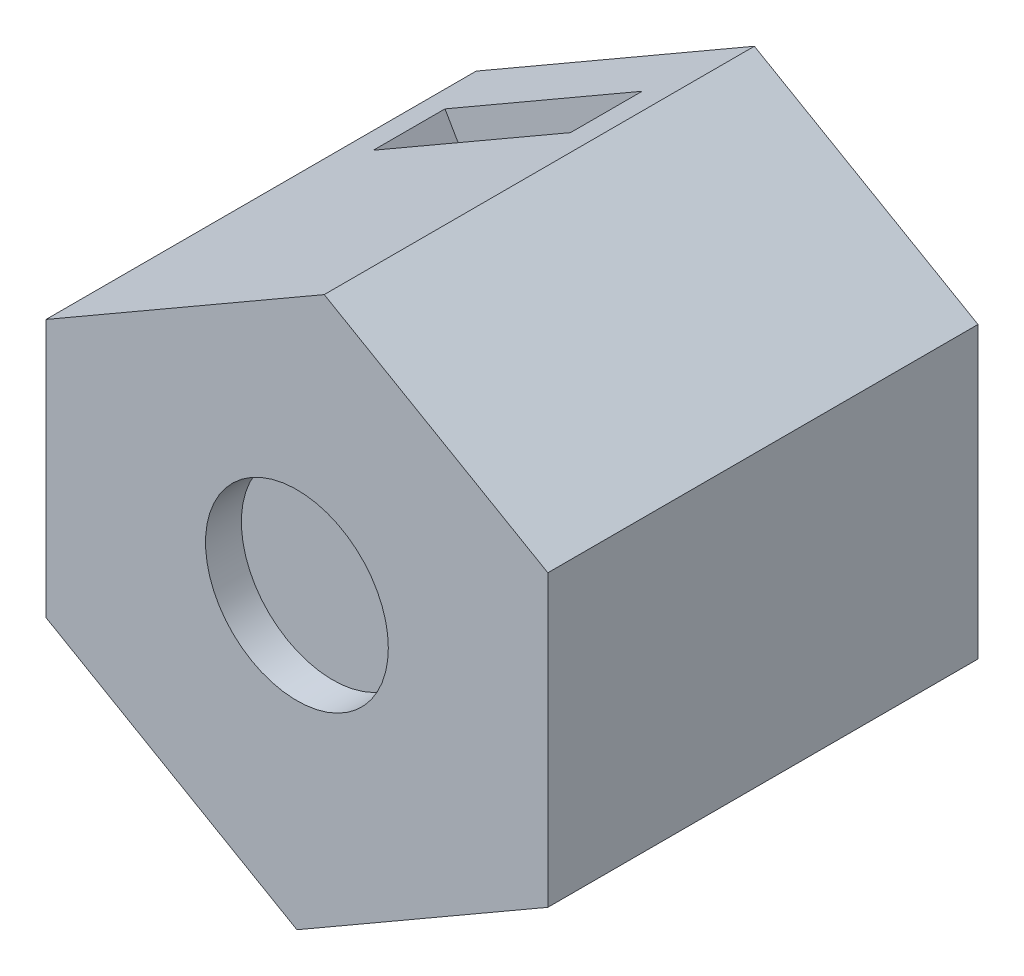
from build123d import *

# Parameters (mm, degrees)
SKETCH1_R           = 7
BOSS_EXTRUDE1_DEPTH = 12
SKETCH2_R           = 2.55
CUT_EXTRUDE1_DEPTH  = 1
SKETCH3_R           = 1.5
CUT_EXTRUDE2_DEPTH  = 4
CUT_EXTRUDE3_DEPTH  = 2
SKETCH5_W           = 6.350852962
SKETCH5_H           = 2
CUT_EXTRUDE4_DEPTH  = 5
SKETCH5_2_W         = 6.350852962
SKETCH5_2_H         = 2
CUT_EXTRUDE5_DEPTH  = 2.7
SKETCH6_R           = 1.5
CUT_EXTRUDE6_DEPTH  = 7
BOSS_EXTRUDE2_DEPTH = 12
CUT_EXTRUDE7_DEPTH  = 12
CUT_EXTRUDE8_DEPTH  = 12


with BuildPart() as part:
    # Sketch1 → Boss-Extrude1 (new body)
    with BuildSketch(Plane.XY):
        Circle(SKETCH1_R)
    extrude(amount=BOSS_EXTRUDE1_DEPTH)

    # Sketch2 → Cut-Extrude1 (cut)
    with BuildSketch(Plane.XY.offset(12)):
        Circle(SKETCH2_R)
    extrude(amount=-CUT_EXTRUDE1_DEPTH, mode=Mode.SUBTRACT)

    # Sketch3 → Cut-Extrude2 (cut)
    with BuildSketch(Plane(origin=(0, 0, 0), x_dir=(-1, 0, 0), z_dir=(0, 0, -1))):
        Circle(SKETCH3_R)
    extrude(amount=-CUT_EXTRUDE2_DEPTH, mode=Mode.SUBTRACT)

    # Sketch4 → Cut-Extrude3 (cut)
    with BuildSketch(Plane(origin=(0, 0, 4), x_dir=(-1, 0, 0), z_dir=(0, 0, -1))):
        Polygon((0, 3.175426481), (-2.75, 1.58771324), (-2.75, -1.58771324), (0, -3.175426481), (2.75, -1.58771324), (2.75, 1.58771324), align=None)
    extrude(amount=CUT_EXTRUDE3_DEPTH, mode=Mode.SUBTRACT)

    # Sketch5 → Cut-Extrude4 (cut)
    with BuildSketch(Plane(origin=(-1.375, 2.38156986, 0), x_dir=(0.866025404, 0.5, 0), z_dir=(0.5, -0.866025404, 0))):
        with Locations((0, 3)):
            Rectangle(SKETCH5_W, SKETCH5_H)
    extrude(amount=-CUT_EXTRUDE4_DEPTH, mode=Mode.SUBTRACT)

    # Sketch5_2 → Cut-Extrude5 (cut)
    with BuildSketch(Plane(origin=(-1.375, 2.38156986, 0), x_dir=(0.866025404, 0.5, 0), z_dir=(0.5, -0.866025404, 0))):
        with Locations((0, 3)):
            Rectangle(SKETCH5_2_W, SKETCH5_2_H)
    extrude(amount=CUT_EXTRUDE5_DEPTH, mode=Mode.SUBTRACT)

    # Sketch6 → Cut-Extrude6 (cut)
    with BuildSketch(Plane(origin=(0, 0, 0), x_dir=(-1, 0, 0), z_dir=(0, 0, -1))):
        Circle(SKETCH6_R)
    extrude(amount=-CUT_EXTRUDE6_DEPTH, mode=Mode.SUBTRACT)

    # Sketch7 → Boss-Extrude2 (add)
    with BuildSketch(Plane.XY.offset(12)):
        with BuildLine():
            Line((-5.869161212, 3.814832456), (-6.25, 4.474464586))
            Line((-6.25, 4.474464586), (-7, 4.041451884))
            Line((-7, 4.041451884), (-7, 0))
            ThreePointArc((-7, 0), (-6.711338484, 1.989456146), (-5.869161212, 3.814832456))
        make_face()
        with BuildLine():
            Line((3.499999838, 6.06217792), (0, 8.082903769))
            Line((0, 8.082903769), (-0.75, 7.649891067))
            Line((-0.75, 7.649891067), (-0.369161212, 6.990258937))
            ThreePointArc((-0.369161212, 6.990258937), (1.632749589, 6.806917715), (3.499999838, 6.06217792))
        make_face()
        with BuildLine():
            Line((7, 4.041451884), (3.499999838, 6.06217792))
            ThreePointArc((3.499999838, 6.06217792), (6.06217778, 3.500000081), (7, 0))
            Line((7, 0), (7, 4.041451884))
        make_face()
        with BuildLine():
            Line((7, -4.041451884), (7, 0))
            ThreePointArc((7, 0), (6.062177778, -3.500000084), (3.499999831, -6.062177924))
            Line((3.499999831, -6.062177924), (7, -4.041451884))
        make_face()
        with BuildLine():
            Line((0, -8.082903769), (3.499999831, -6.062177924))
            ThreePointArc((3.499999831, -6.062177924), (-1.13e-07, -7), (-3.500000026, -6.062177811))
            Line((-3.500000026, -6.062177811), (0, -8.082903769))
        make_face()
        with BuildLine():
            ThreePointArc((-3.500000026, -6.062177811), (-6.062177834, -3.499999987), (-7, 0))
            Line((-7, 0), (-7, -4.041451884))
            Line((-7, -4.041451884), (-3.500000026, -6.062177811))
        make_face()
    extrude(amount=-BOSS_EXTRUDE2_DEPTH)

    # Sketch7_4 → Cut-Extrude7 (cut)
    with BuildSketch(Plane.XY.offset(12)):
        with BuildLine():
            ThreePointArc((-0.369161212, 6.990258937), (-1.989456099, 6.711338498), (-3.499999915, 6.062177876))
            ThreePointArc((-3.499999915, 6.062177876), (-4.817461512, 5.078588838), (-5.869161212, 3.814832456))
            Line((-5.869161212, 3.814832456), (-0.369161212, 6.990258937))
        make_face()
    extrude(amount=-CUT_EXTRUDE7_DEPTH, mode=Mode.SUBTRACT)

    # Sketch8 → Cut-Extrude8 (cut)
    with BuildSketch(Plane.XY.offset(12)):
        Polygon((-7, 3.161942377), (-5.869161212, 3.814832456), (-6.25, 4.474464586), (-7, 4.041451884), align=None)
        Polygon((-0.75, 7.649891067), (-0.369161212, 6.990258937), (0.761677576, 7.643149015), (0, 8.082903769), align=None)
    extrude(amount=-CUT_EXTRUDE8_DEPTH, mode=Mode.SUBTRACT)


solid = part.part
